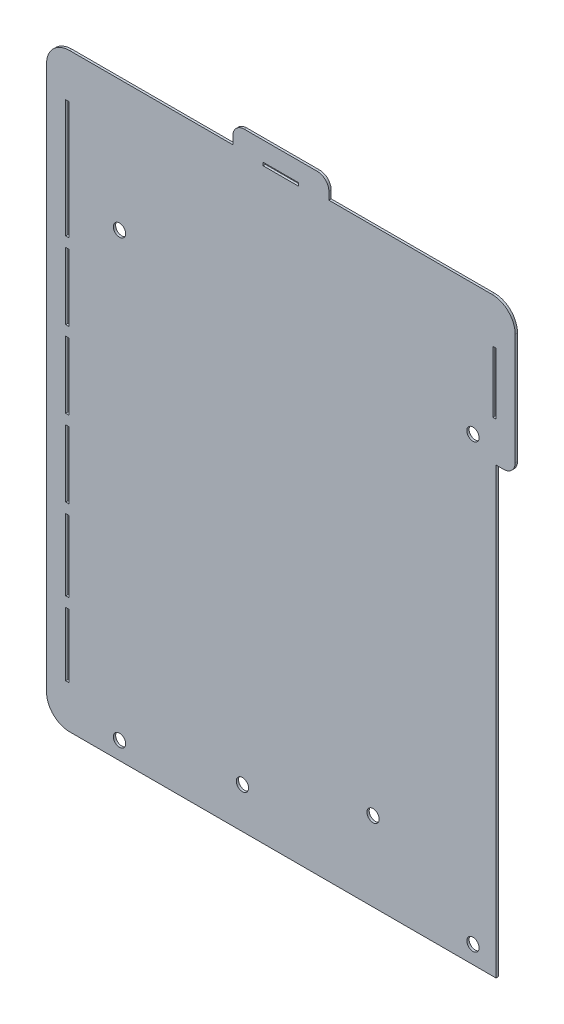
from build123d import *

# Parameters (mm, degrees)
BOSS_EXTRUDE1_DEPTH = 0.6
SKETCH14_R          = 1.6
SKETCH14_W          = 0.8
SKETCH14_H          = 30.7
SKETCH14_H_2        = 16.55
SKETCH14_H_3        = 17.4
SKETCH14_H_4        = 18.55
SKETCH14_H_5        = 16
CUT_EXTRUDE1_DEPTH  = 1.6
FILLET3_R           = 6
SKETCH15_R          = 1.6
CUT_EXTRUDE2_DEPTH  = 1.6
SKETCH16_W          = 25
SKETCH16_H          = 5
BOSS_EXTRUDE2_DEPTH = 0.6
SKETCH17_W          = 9.2
SKETCH17_H          = 0.8
CUT_EXTRUDE3_DEPTH  = 1.6
FILLET4_R           = 3


with BuildPart() as part:
    # Sketch2 → Boss-Extrude1 (new body)
    with BuildSketch(Plane.XY):
        Polygon((106.16728925, 147.241288665), (106.16728925, 31.58105), (24.16705825, 31.58105), (-10.832812, 31.58105), (-10.832812, 185.1806075), (24.16705825, 185.1806075), (106.16728925, 185.1806075), (111.16728925, 185.1806075), (111.16728925, 147.241288665), align=None)
    extrude(amount=BOSS_EXTRUDE1_DEPTH)

    # Sketch14 → Cut-Extrude1 (cut, through all)
    with BuildSketch(Plane.XY.offset(0.6)):
        with Locations((100.166839875, 36.181495)):
            Circle(SKETCH14_R)
        with Locations((8.167632375, 36.181495)):
            Circle(SKETCH14_R)
        with Locations((8.167632375, 151.18016)):
            Circle(SKETCH14_R)
        with Locations((100.166839875, 151.18016)):
            Circle(SKETCH14_R)
        with Locations((-5.432812, 158.23105)):
            Rectangle(SKETCH14_W, SKETCH14_H)
        with Locations((-5.432812, 50.85605)):
            Rectangle(SKETCH14_W, SKETCH14_H_2)
        with Locations((-5.432812, 131.58105)):
            Rectangle(SKETCH14_W, SKETCH14_H_3)
        with Locations((-5.432812, 71.00605)):
            Rectangle(SKETCH14_W, SKETCH14_H_4)
        with Locations((-5.432812, 91.58105)):
            Rectangle(SKETCH14_W, SKETCH14_H_3)
        with Locations((-5.432812, 111.58105)):
            Rectangle(SKETCH14_W, SKETCH14_H_3)
        with Locations((105.76728925, 165.58105)):
            Rectangle(SKETCH14_W, SKETCH14_H_5)
    extrude(amount=-CUT_EXTRUDE1_DEPTH, mode=Mode.SUBTRACT)

    # Fillet3
    fillet3_edges = [part.edges().sort_by_distance(p)[0] for p in [
        (111.16728925, 185.1806075, 0.3),
        (-10.832812, 31.58105, 0.3),
        (-10.832812, 185.1806075, 0.3),
    ]]
    fillet(fillet3_edges, radius=FILLET3_R)

    # Sketch15 → Cut-Extrude2 (cut, through all)
    with BuildSketch(Plane.XY.offset(0.6)):
        with Locations((74.166839875, 52.181495)):
            Circle(SKETCH15_R)
        with Locations((40.166839875, 42.181495)):
            Circle(SKETCH15_R)
    extrude(amount=-CUT_EXTRUDE2_DEPTH, mode=Mode.SUBTRACT)

    # Sketch16 → Boss-Extrude2 (add)
    with BuildSketch(Plane.XY.offset(0.6)):
        with Locations((50.16728925, 187.6806075)):
            Rectangle(SKETCH16_W, SKETCH16_H)
    extrude(amount=-BOSS_EXTRUDE2_DEPTH)

    # Sketch17 → Cut-Extrude3 (cut, through all)
    with BuildSketch(Plane.XY.offset(0.6)):
        with Locations((50.16728925, 184.7806075)):
            Rectangle(SKETCH17_W, SKETCH17_H)
    extrude(amount=-CUT_EXTRUDE3_DEPTH, mode=Mode.SUBTRACT)

    # Fillet4
    fillet4_edges = [part.edges().sort_by_distance(p)[0] for p in [
        (111.16728925, 147.241288665, 0.3),
        (37.66728925, 190.1806075, 0.3),
        (62.66728925, 190.1806075, 0.3),
    ]]
    fillet(fillet4_edges, radius=FILLET4_R)


solid = part.part
